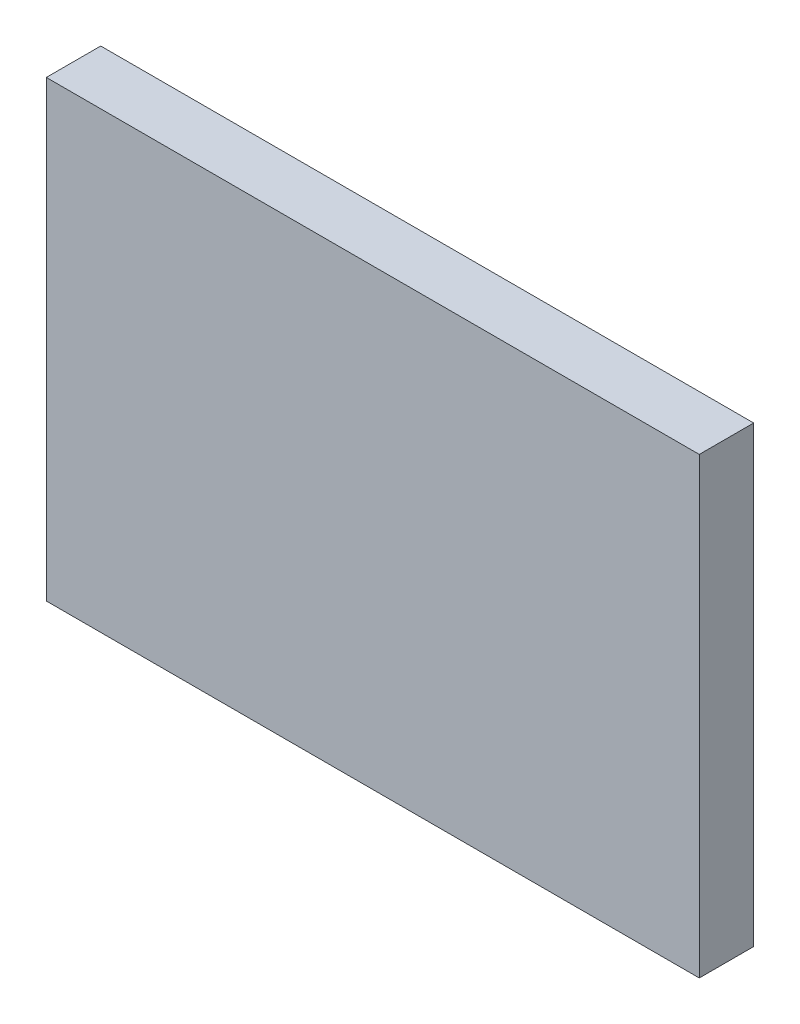
from build123d import *

# Parameters (mm, degrees)
SKETCH1_W           = 36
SKETCH1_H           = 25
BOSS_EXTRUDE1_DEPTH = 3


with BuildPart() as part:
    # Sketch1 → Boss-Extrude1 (new body)
    with BuildSketch(Plane.XY):
        with Locations((18, -12.5)):
            Rectangle(SKETCH1_W, SKETCH1_H)
    extrude(amount=BOSS_EXTRUDE1_DEPTH)


solid = part.part
